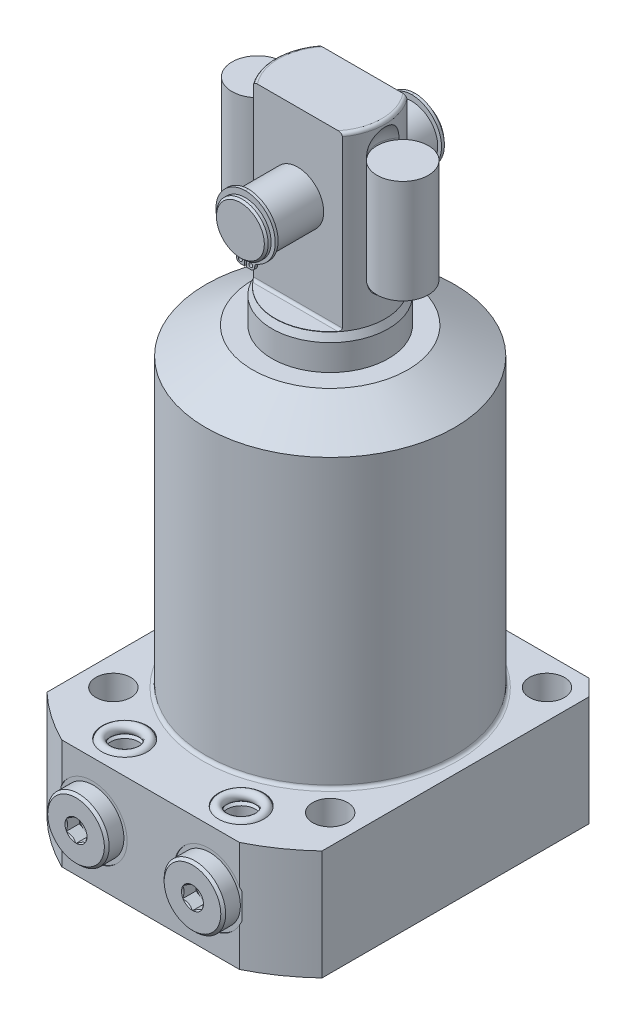
from build123d import *

# Parameters (mm, degrees)
FLATS_DEPTH            = 50
SKETCH23_R             = 0.595
RETAINING_RING_DEPTH   = 0.89
SKETCH24_W             = 7.9375
SKETCH24_H             = 32
SKETCH7_OUTSIDE_W      = 178.138
SKETCH7_OUTSIDE_H      = 178.138
SKETCH7_OUTSIDE_W_2    = 85
SKETCH7_OUTSIDE_H_2    = 98
FLANGE_SIDES_DEPTH     = 35
SKETCH8_R              = 5.4
MOUNTING_HOLES_DEPTH   = 195.2500001
MOUNTING_PATTERN_COUNT = 4
FLANGE_CHAMFER_SIZE    = 5
BODY_FILLET_R          = 1
BSPP_PLUG_HEX_DEPTH    = 4.06
SKETCH16_R             = 1.5


with BuildPart() as part:
    # Sketch1 → PLUNGER (revolve)
    with BuildSketch(Plane.XY, mode=Mode.PRIVATE) as plunger_sk:
        with BuildLine():
            Line((18, 0), (18, 105))
            Line((18, 105), (17, 107.144506921))
            Line((17, 107.144506921), (17, 159.25))
            ThreePointArc((17, 159.25), (16.707106781, 159.957106781), (16, 160.25))
            Line((16, 160.25), (0, 160.25))
            Line((0, 160.25), (0, 0))
            Line((0, 0), (18, 0))
        make_face()
    revolve(plunger_sk.sketch.rotate(Axis((0, -3.075, 0), (0, 1, 0)), 90), axis=Axis((0, -3.075, 0), (0, 1, 0)))  # turned: the seam where the file's is

    # Sketch17 → FLATS (cut, symmetric)
    with BuildSketch(Plane(origin=(0, 0, 0), x_dir=(0, 0, -1), z_dir=(1, 0, 0))):
        with BuildLine():
            Line((10, 160.25), (17, 160.25))
            Line((17, 160.25), (17, 107.25))
            Line((17, 107.25), (10.8, 107.25))
            ThreePointArc((10.8, 107.25), (10.234314575, 107.484314575), (10, 108.05))
            Line((10, 108.05), (10, 160.25))
        make_face()
        with BuildLine():
            Line((-17, 160.25), (-17, 107.25))
            Line((-17, 107.25), (-10.8, 107.25))
            ThreePointArc((-10.8, 107.25), (-10.234314575, 107.484314575), (-10, 108.05))
            Line((-10, 108.05), (-10, 160.25))
            Line((-10, 160.25), (-17, 160.25))
        make_face()
    extrude(amount=FLATS_DEPTH, both=True, mode=Mode.SUBTRACT)

    # Sketch22 → PIVOT_PIN (revolve)
    with BuildSketch(Plane(origin=(0, 0, 0), x_dir=(0, 0, -1), z_dir=(1, 0, 0)), mode=Mode.PRIVATE) as pivot_pin_sk:
        Polygon((-27.75, 143.65), (-27.15, 144.25), (-26.25, 144.25), (-26.25, 143.7175), (-25.25, 143.7175), (-25.25, 144.25), (25.25, 144.25), (25.25, 143.7175), (26.25, 143.7175), (26.25, 144.25), (27.15, 144.25), (27.75, 143.65), (27.75, 136.25), (-27.75, 136.25), align=None)
    revolve(pivot_pin_sk.sketch.rotate(Axis((0, 136.25, 11.568872367), (0, 0, -1)), 90), axis=Axis((0, 136.25, 11.568872367), (0, 0, -1)))  # turned: the seam where the file's is

    # Sketch23 → RETAINING_RING (add)
    with BuildSketch(Plane(origin=(0, 0, -25.25), x_dir=(-1, 0, 0), z_dir=(0, 0, -1))):
        with BuildLine():
            Line((-0.35, 125.70790726), (-1.61, 125.70790726))
            ThreePointArc((-1.61, 125.70790726), (-2.45145707, 126.05645019), (-2.8, 126.89790726))
            ThreePointArc((-2.8, 126.89790726), (-3.016409951, 127.62681713), (-3.595517448, 128.11954157))
            ThreePointArc((-3.595517448, 128.11954157), (-8.984429795, 138.517492161), (0, 146.03))
            ThreePointArc((0, 146.03), (8.984429795, 138.517492161), (3.595517448, 128.11954157))
            ThreePointArc((3.595517448, 128.11954157), (3.016409951, 127.62681713), (2.8, 126.89790726))
            ThreePointArc((2.8, 126.89790726), (2.45145707, 126.05645019), (1.61, 125.70790726))
            Line((1.61, 125.70790726), (0.35, 125.70790726))
            Line((0.35, 125.70790726), (0.35, 128.50790726))
            ThreePointArc((0.35, 128.50790726), (0, 144), (-0.35, 128.50790726))
            Line((-0.35, 128.50790726), (-0.35, 125.70790726))
        make_face()
        with Locations((-1.61, 126.89790726)):
            Circle(SKETCH23_R, mode=Mode.SUBTRACT)
        with Locations(Location((1.61, 126.89790726, 0), (0, 0, 180))):  # turned: the seam where the file's is
            Circle(SKETCH23_R, mode=Mode.SUBTRACT)
    retaining_ring = extrude(amount=RETAINING_RING_DEPTH)

    # RETAINING_RING-OPP: RETAINING_RING across plane
    add(retaining_ring.mirror(Plane.XY))

    # Sketch20 → SPRING_SLOT (revolve, cut)
    with BuildSketch(Plane.XY):
        with BuildLine():
            Line((14.5, 152.75), (14.5, 119.75))
            ThreePointArc((14.5, 119.75), (16.824839924, 114.137339924), (22.4375, 111.8125))
            Line((22.4375, 111.8125), (22.4375, 160.6875))
            ThreePointArc((22.4375, 160.6875), (16.824839924, 158.362660076), (14.5, 152.75))
        make_face()
    spring_slot = revolve(axis=Axis((22.4375, 82.047956129, 0), (0, -1, 0)), mode=Mode.SUBTRACT)

    # SPRING_SLOT_OPP: SPRING_SLOT across plane
    add(spring_slot.mirror(Plane(origin=(0, 0, 0), x_dir=(0, 0, 1), z_dir=(1, 0, 0))), mode=Mode.SUBTRACT)

    # Sketch24 → SPRING (revolve)
    with BuildSketch(Plane.XY):
        with Locations((-18.43875, 136.25)):
            Rectangle(SKETCH24_W, SKETCH24_H)
    spring = revolve(axis=Axis((-22.4075, 84.567834264, 0), (0, -1, 0)))

    # SPRING_OPP: SPRING across plane
    add(spring.mirror(Plane(origin=(0, 0, 0), x_dir=(0, 0, 1), z_dir=(1, 0, 0))))

    # Sketch6 → BODY_REVOLVE (revolve)
    with BuildSketch(Plane.XY, mode=Mode.PRIVATE) as body_revolve_sk:
        Polygon((0, 97), (24, 97), (38.385, 88.694816378), (38.385, 0), (61.915, 0), (61.915, -34), (0, -34), align=None)
    revolve(body_revolve_sk.sketch.rotate(Axis((0, -34, 0), (0, 1, 0)), 90), axis=Axis((0, -34, 0), (0, 1, 0)))  # turned: the seam where the file's is

    # Sketch7 outside → FLANGE_SIDES (cut, through all)
    with BuildSketch(Plane(origin=(0, 0, 0), x_dir=(-1, 0, 0), z_dir=(0, 1, 0))):
        Rectangle(SKETCH7_OUTSIDE_W, SKETCH7_OUTSIDE_H)
        with Locations((0, 6.5)):
            Rectangle(SKETCH7_OUTSIDE_W_2, SKETCH7_OUTSIDE_H_2, mode=Mode.SUBTRACT)
    extrude(amount=-FLANGE_SIDES_DEPTH, mode=Mode.SUBTRACT)

    # Sketch8 → MOUNTING HOLES (cut, through all)
    with BuildSketch(Plane.XZ.offset(34)):
        with Locations(Location((-33.5, 33.5, 0), (0, 0, 270))):  # turned: the seam where the file's is
            Circle(SKETCH8_R)
    mounting_holes = extrude(amount=-MOUNTING_HOLES_DEPTH, mode=Mode.SUBTRACT)

    # MOUNTING_PATTERN: MOUNTING HOLES ×4 about axis
    mounting_pattern_axis = Axis((0, 0, 0), (0, 1, 0))
    for i in range(1, MOUNTING_PATTERN_COUNT):
        add(mounting_holes.rotate(mounting_pattern_axis, i * 360 / MOUNTING_PATTERN_COUNT), mode=Mode.SUBTRACT)

    # FLANGE_CHAMFER
    flange_chamfer_edges = [part.edges().sort_by_distance(p)[0] for p in [
        (-42.5, -17, -42.5),
        (42.5, -17, -42.5),
    ]]
    chamfer(flange_chamfer_edges, length=FLANGE_CHAMFER_SIZE)

    # BODY_FILLET
    body_fillet_edges = [part.edges().sort_by_distance(p)[0] for p in [
        (0, 0, 38.385),
    ]]
    fillet(body_fillet_edges, radius=BODY_FILLET_R)

    # Sketch11 → PORT SPOT FACE (revolve, cut)
    with BuildSketch(Plane.XZ.offset(17), mode=Mode.PRIVATE) as port_spot_face_sk:
        Polygon((-28.75, 55.5), (-28.75, 55.25), (-24.65, 55.25), (-23.945, 54.545), (-23.945, 36.53), (-18, 36.53), (-18, 55.5), align=None)
    port_spot_face = revolve(port_spot_face_sk.sketch.rotate(Axis((-18, -17, 42.971570338), (0, 0, -1)), 180), axis=Axis((-18, -17, 42.971570338), (0, 0, -1)), mode=Mode.SUBTRACT)  # turned: the seam where the file's is

    # Sketch13 → BOTTOM_MANIFOLD_PORT (revolve, cut)
    with BuildSketch(Plane.XY.offset(45.5)):
        Polygon((-22.375, -22), (-22.375, -31), (-23.125, -31.75), (-25, -31.75), (-25, -34), (-18, -34), (-18, -22), align=None)
    bottom_manifold_port = revolve(axis=Axis((-18, 15.209907045, 45.5), (0, -1, 0)), mode=Mode.SUBTRACT)

    # Sketch14 → BSPP_PLUGHEAD (revolve)
    with BuildSketch(Plane.XZ.offset(17)):
        Polygon((-21.4, 60.55), (-26.75, 60.55), (-27.5, 59.8), (-27.5, 55.25), (-22.125, 55.25), (-22.125, 52.7472), (-18, 52.7472), (-18, 52.7482), (-21, 54.550781857), (-21, 60.15), align=None)
    bspp_plughead = revolve(axis=Axis((-18, -17, 32.588064048), (0, 0, 1)))

    # Sketch15 → BSPP_PLUG_HEX (cut)
    with BuildSketch(Plane.XY.offset(60.55)):
        Polygon((-15, -18.732050808), (-15, -15.267949192), (-18, -13.535898385), (-21, -15.267949192), (-21, -18.732050808), (-18, -20.464101615), align=None)
    bspp_plug_hex = extrude(amount=-BSPP_PLUG_HEX_DEPTH, mode=Mode.SUBTRACT)

    # MANIFOLD_TOP_MIRROR: BOTTOM_MANIFOLD_PORT across plane
    add(bottom_manifold_port.mirror(Plane(origin=(0, -17, 0), x_dir=(0, 0, 1), z_dir=(0, -1, 0))), mode=Mode.SUBTRACT)

    # BSPP-MANIFOLD_MIRROR: PORT SPOT FACE, BOTTOM_MANIFOLD_PORT, BSPP_PLUGHEAD, BSPP_PLUG_HEX across plane
    add(port_spot_face.mirror(Plane(origin=(0, 0, 0), x_dir=(0, 0, 1), z_dir=(1, 0, 0))), mode=Mode.SUBTRACT)
    add(bottom_manifold_port.mirror(Plane(origin=(0, 0, 0), x_dir=(0, 0, 1), z_dir=(1, 0, 0))), mode=Mode.SUBTRACT)
    add(bspp_plughead.mirror(Plane(origin=(0, 0, 0), x_dir=(0, 0, 1), z_dir=(1, 0, 0))))
    add(bspp_plug_hex.mirror(Plane(origin=(0, 0, 0), x_dir=(0, 0, 1), z_dir=(1, 0, 0))), mode=Mode.SUBTRACT)

    # BSPP-MANIFOLD_MIRROR copy 1 sketch → BSPP-MANIFOLD_MIRROR copy 1 (revolve, cut)
    with BuildSketch(Plane(origin=(0, -34, 45.5), x_dir=(-1, 0, 0), z_dir=(0, 0, 1))):
        Polygon((-22.375, -22), (-22.375, -31), (-23.125, -31.75), (-25, -31.75), (-25, -34), (-18, -34), (-18, -22), align=None)
    revolve(axis=Axis((18, -49.209907045, 45.5), (0, 1, 0)), mode=Mode.SUBTRACT)


with BuildPart() as body_2:
    # Sketch16 → MANIFOLD_O-RING (revolve)
    with BuildSketch(Plane.XY.offset(45.5)):
        with Locations((-23.5, -33.25)):
            Circle(SKETCH16_R)
    revolve(axis=Axis((-18, 9.321927472, 45.5), (0, -1, 0)))


with BuildPart() as body_3:
    # MANIFOLD_O-RING_MIRROR: mirrored copy
    add(body_2.part.mirror(Plane(origin=(0, 0, 0), x_dir=(0, 0, 1), z_dir=(1, 0, 0))))


with BuildPart() as body_4:
    # MANIFOLD_O-RING_MIRROR_TOP: mirrored copy
    add(body_2.part.mirror(Plane(origin=(0, -17, 0), x_dir=(0, 0, 1), z_dir=(0, -1, 0))))


with BuildPart() as body_5:
    # MANIFOLD_O-RING_MIRROR_TOP 2: mirrored copy
    add(body_3.part.mirror(Plane(origin=(0, -17, 0), x_dir=(0, 0, 1), z_dir=(0, -1, 0))))


solid = Compound([part.part, body_2.part, body_3.part, body_4.part, body_5.part])
